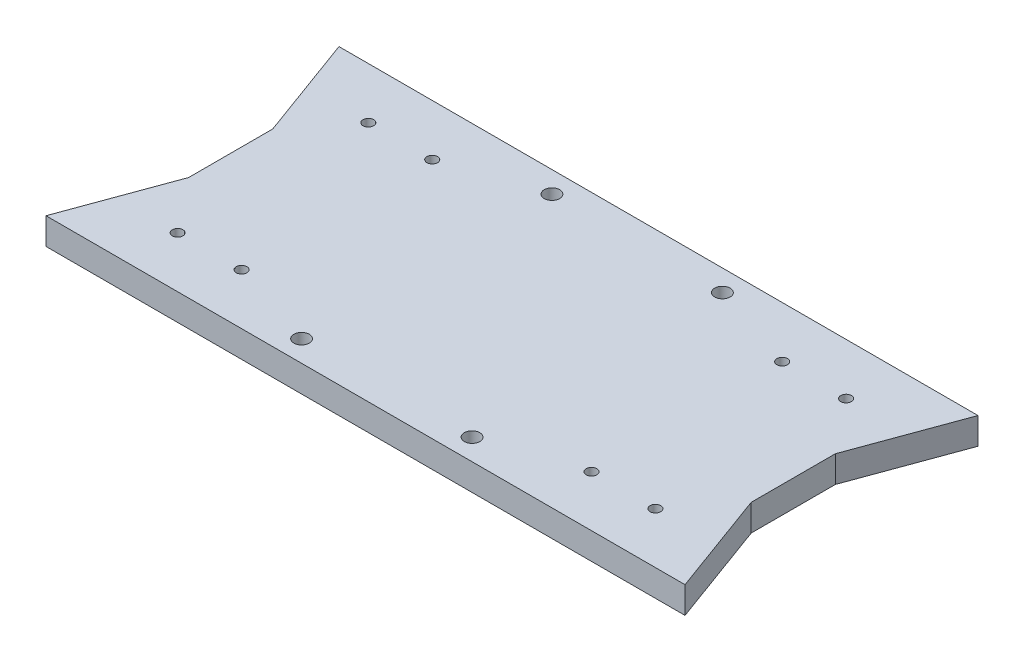
from build123d import *

# Parameters (mm, degrees)
SKETCH1_W           = 67.061286962
SKETCH1_H           = 69.85
SKETCH1_R           = 1.27
BOSS_EXTRUDE1_DEPTH = 6.35
SKETCH2_W           = 20.976278342
SKETCH2_H           = 20.060000012
BOSS_EXTRUDE2_DEPTH = 12.7
BOSS_EXTRUDE3_DEPTH = 6.35
SKETCH4_W           = 170.998259203
SKETCH4_H           = 17.997071231
CUT_EXTRUDE1_DEPTH  = 70.85
SKETCH8_R           = 1.8415
CUT_EXTRUDE3_DEPTH  = 13.716


with BuildPart() as part:
    # Sketch1 → Boss-Extrude1 (new body)
    with BuildSketch(Plane(origin=(0, 0, 0), x_dir=(1, 0, 0), z_dir=(0, 1, 0))):
        with Locations((-4.803022, 67.707661351)):
            Rectangle(SKETCH1_W, SKETCH1_H)
        with Locations((3.381343157, 90.407661351)):
            Circle(SKETCH1_R, mode=Mode.SUBTRACT)
        with Locations((18.621343157, 90.407661351)):
            Circle(SKETCH1_R, mode=Mode.SUBTRACT)
        with Locations((3.381343157, 44.947661351)):
            Circle(SKETCH1_R, mode=Mode.SUBTRACT)
        with Locations((18.621343157, 44.947661351)):
            Circle(SKETCH1_R, mode=Mode.SUBTRACT)
    boss_extrude1 = extrude(amount=BOSS_EXTRUDE1_DEPTH)

    # Sketch2 → Boss-Extrude2 (add)
    with BuildSketch(Plane(origin=(0, 6.35, 0), x_dir=(1, 0, 0), z_dir=(0, 1, 0))):
        with Locations((18.23948231, 67.707661351)):
            Rectangle(SKETCH2_W, SKETCH2_H)
    boss_extrude2 = extrude(amount=BOSS_EXTRUDE2_DEPTH)

    # Sketch3 → Boss-Extrude3 (add)
    with BuildSketch(Plane(origin=(0, 6.35, 0), x_dir=(1, 0, 0), z_dir=(0, 1, 0))):
        Polygon((37.841343157, 102.632661351), (28.727621481, 77.737661357), (28.727621481, 102.632661351), align=None)
        Polygon((28.727621481, 57.677661345), (37.841343157, 32.782661351), (28.727621481, 32.782661351), align=None)
    boss_extrude3 = extrude(amount=-BOSS_EXTRUDE3_DEPTH)

    # Mirror2: Boss-Extrude1, Boss-Extrude2, Boss-Extrude3 across plane
    add(boss_extrude1.mirror(Plane(origin=(-38.333665481, 6.35, -32.782661351), x_dir=(0, 0, 1), z_dir=(1, 0, 0))))
    add(boss_extrude2.mirror(Plane(origin=(-38.333665481, 6.35, -32.782661351), x_dir=(0, 0, 1), z_dir=(1, 0, 0))))
    add(boss_extrude3.mirror(Plane(origin=(-38.333665481, 6.35, -32.782661351), x_dir=(0, 0, 1), z_dir=(1, 0, 0))))

    # Sketch4 → Cut-Extrude1 (cut, through all)
    with BuildSketch(Plane.XY.offset(-32.782661351)):
        with Locations((-47.657786445, 15.348535616)):
            Rectangle(SKETCH4_W, SKETCH4_H)
    extrude(amount=-CUT_EXTRUDE1_DEPTH, mode=Mode.SUBTRACT)

    # Sketch8 → Cut-Extrude3 (cut)
    with BuildSketch(Plane(origin=(0, 6.35, 0), x_dir=(1, 0, 0), z_dir=(0, 1, 0))):
        with Locations((-58.653665481, 97.552661351)):
            Circle(SKETCH8_R)
        with Locations((-18.013665481, 97.552661351)):
            Circle(SKETCH8_R)
        with Locations((-18.013665481, 37.862661351)):
            Circle(SKETCH8_R)
        with Locations((-58.653665481, 37.862661351)):
            Circle(SKETCH8_R)
    extrude(amount=-CUT_EXTRUDE3_DEPTH, mode=Mode.SUBTRACT)


solid = part.part
